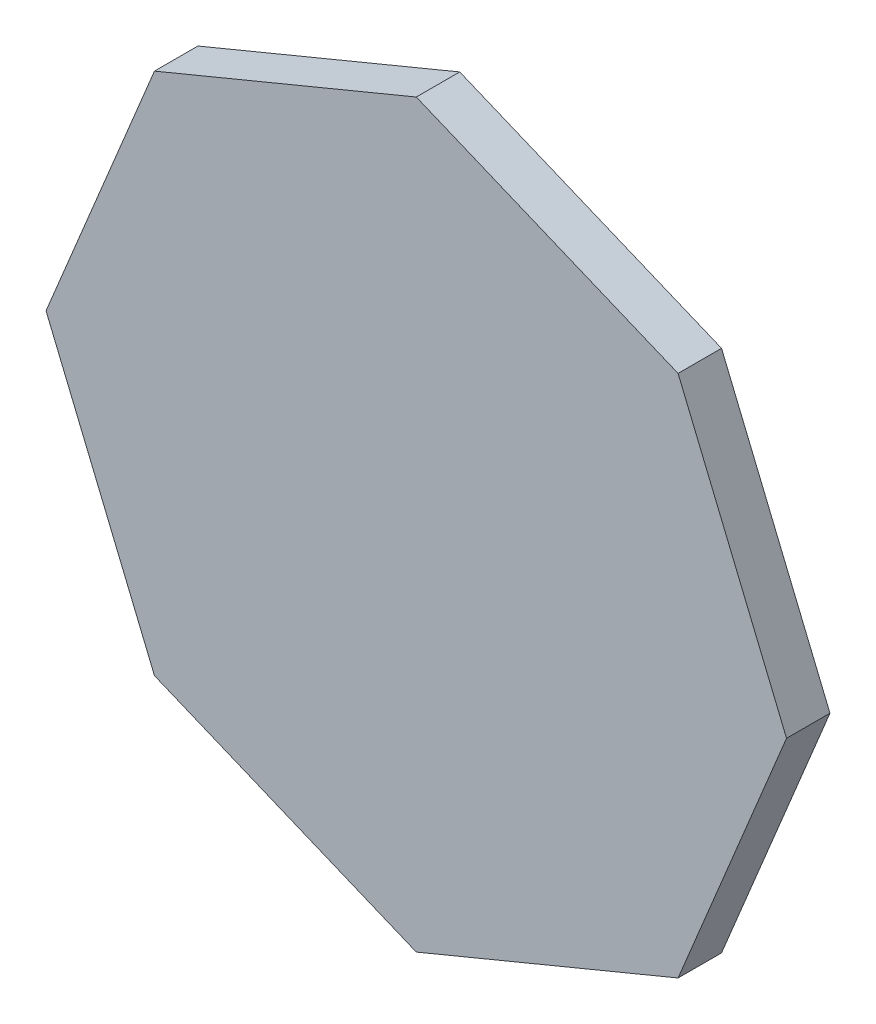
from build123d import *

# Parameters (mm, degrees)
BOSS_EXTRUDE1_DEPTH     = 3
SKETCH5_W               = 150
SKETCH5_H               = 20
BOSS_EXTRUDE2_DEPTH     = 3
MIRROR2_COPY_1_SKETCH_W = 150
MIRROR2_COPY_1_SKETCH_H = 20
MIRROR2_COPY_1_DEPTH    = 3
SKETCH6_W               = 23
SKETCH6_H               = 150
BOSS_EXTRUDE3_DEPTH     = 3
MIRROR4_COPY_1_SKETCH_W = 23
MIRROR4_COPY_1_SKETCH_H = 150
MIRROR4_COPY_1_DEPTH    = 3
MIRROR4_COPY_2_SKETCH_W = 23
MIRROR4_COPY_2_SKETCH_H = 150
MIRROR4_COPY_2_DEPTH    = 3
FILLET1_R               = 2


with BuildPart() as part:
    # Sketch1 → Boss-Extrude1 (new body)
    with BuildSketch(Plane.XY):
        Polygon((0, 195.984444731), (-138.581929877, 138.581929877), (-195.984444731, 0), (-138.581929877, -138.581929877), (0, -195.984444731), (138.581929877, -138.581929877), (195.984444731, 0), (138.581929877, 138.581929877), align=None)
    boss_extrude1 = extrude(amount=BOSS_EXTRUDE1_DEPTH)

    # Sketch5 → Boss-Extrude2 (add)
    with BuildSketch(Plane(origin=(-69.290964938, -167.283187304, 0), x_dir=(0.923879533, -0.382683432, 0), z_dir=(-0.382683432, -0.923879533, 0))):
        with Locations((0, -10)):
            Rectangle(SKETCH5_W, SKETCH5_H)
    boss_extrude2 = extrude(amount=-BOSS_EXTRUDE2_DEPTH)

    # Mirror1: Boss-Extrude2 across plane
    add(boss_extrude2.mirror(Plane.ZX))

    # Mirror2: Boss-Extrude2 across plane
    add(boss_extrude2.mirror(Plane(origin=(0, 0, 0), x_dir=(0, 0, 1), z_dir=(1, 0, 0))))

    # Mirror2 copy 1 sketch → Mirror2 copy 1 (add)
    with BuildSketch(Plane(origin=(69.290964938, 167.283187304, 0), x_dir=(-0.923879533, 0.382683432, 0), z_dir=(0.382683432, 0.923879533, 0))):
        with Locations((0, -10)):
            Rectangle(MIRROR2_COPY_1_SKETCH_W, MIRROR2_COPY_1_SKETCH_H)
    extrude(amount=-MIRROR2_COPY_1_DEPTH)

    # Sketch6 → Boss-Extrude3 (add)
    with BuildSketch(Plane(origin=(-167.283187304, -69.290964938, 0), x_dir=(0, 0, 1), z_dir=(-0.923879533, -0.382683432, 0))):
        with Locations((-8.5, 0)):
            Rectangle(SKETCH6_W, SKETCH6_H)
    boss_extrude3 = extrude(amount=-BOSS_EXTRUDE3_DEPTH)

    # Mirror3: Boss-Extrude3 across plane
    add(boss_extrude3.mirror(Plane.ZX))

    # Mirror4: Boss-Extrude1 across plane
    add(boss_extrude1.mirror(Plane(origin=(0, 0, 0), x_dir=(0, 0, 1), z_dir=(1, 0, 0))))

    # Mirror4 copy 1 sketch → Mirror4 copy 1 (add)
    with BuildSketch(Plane(origin=(167.283187304, 69.290964938, 0), x_dir=(0, 0, 1), z_dir=(0.923879533, 0.382683432, 0))):
        with Locations((-8.5, 0)):
            Rectangle(MIRROR4_COPY_1_SKETCH_W, MIRROR4_COPY_1_SKETCH_H)
    extrude(amount=-MIRROR4_COPY_1_DEPTH)

    # Mirror4 copy 2 sketch → Mirror4 copy 2 (add)
    with BuildSketch(Plane(origin=(167.283187304, -69.290964938, 0), x_dir=(0, 0, 1), z_dir=(0.923879533, -0.382683432, 0))):
        with Locations((-8.5, 0)):
            Rectangle(MIRROR4_COPY_2_SKETCH_W, MIRROR4_COPY_2_SKETCH_H)
    extrude(amount=-MIRROR4_COPY_2_DEPTH)

    # Fillet1
    fillet1_edges = [part.edges().sort_by_distance(p)[0] for p in [
        (-164.511548707, -68.142914641, 0),
        (-164.511548707, 68.142914641, 0),
        (164.511548707, 68.142914641, 0),
        (164.511548707, -68.142914641, 0),
        (-68.142914641, 164.511548707, 0),
        (68.142914641, 164.511548707, 0),
        (-68.142914641, -164.511548707, 0),
        (68.142914641, -164.511548707, 0),
    ]]
    fillet(fillet1_edges, radius=FILLET1_R)


solid = part.part
